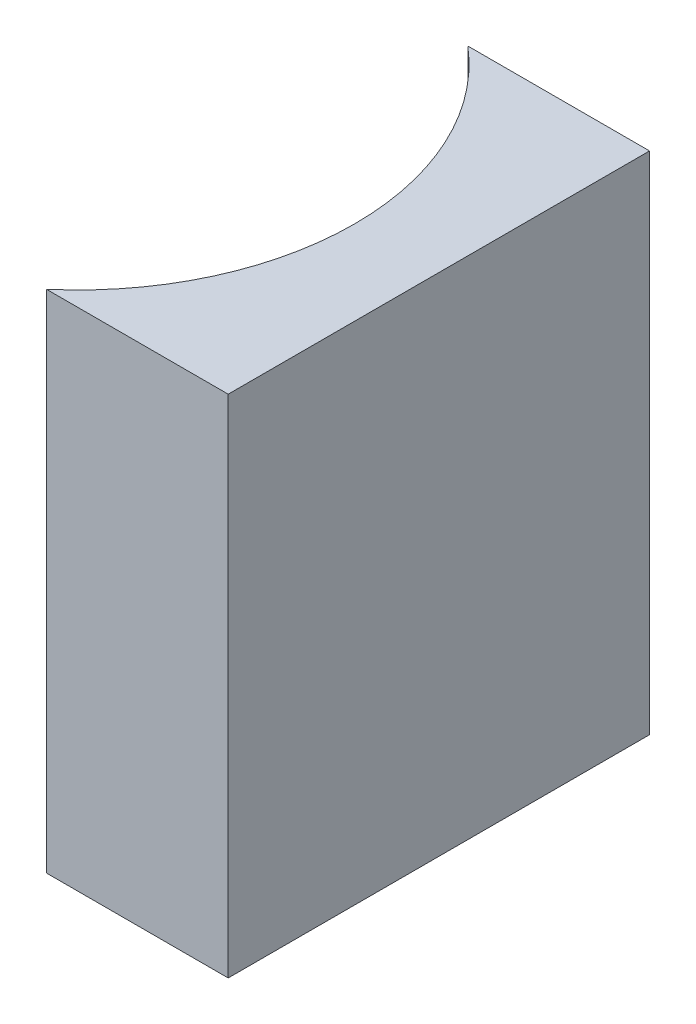
from build123d import *

# Parameters (mm, degrees)
EXTRUDE_1_DEPTH = 12


with BuildPart() as part:
    # 草图1 → 凸台-拉伸1 (new body)
    with BuildSketch(Plane(origin=(0, 0, 0), x_dir=(1, 0, 0), z_dir=(0, 1, 0))):
        with BuildLine():
            Line((0, 0), (0, -10))
            Line((0, -10), (-4.313401361, -10))
            ThreePointArc((-4.313401361, -10), (-2, -5), (-4.313401361, 0))
            Line((-4.313401361, 0), (0, 0))
        make_face()
    extrude(amount=EXTRUDE_1_DEPTH)


solid = part.part
